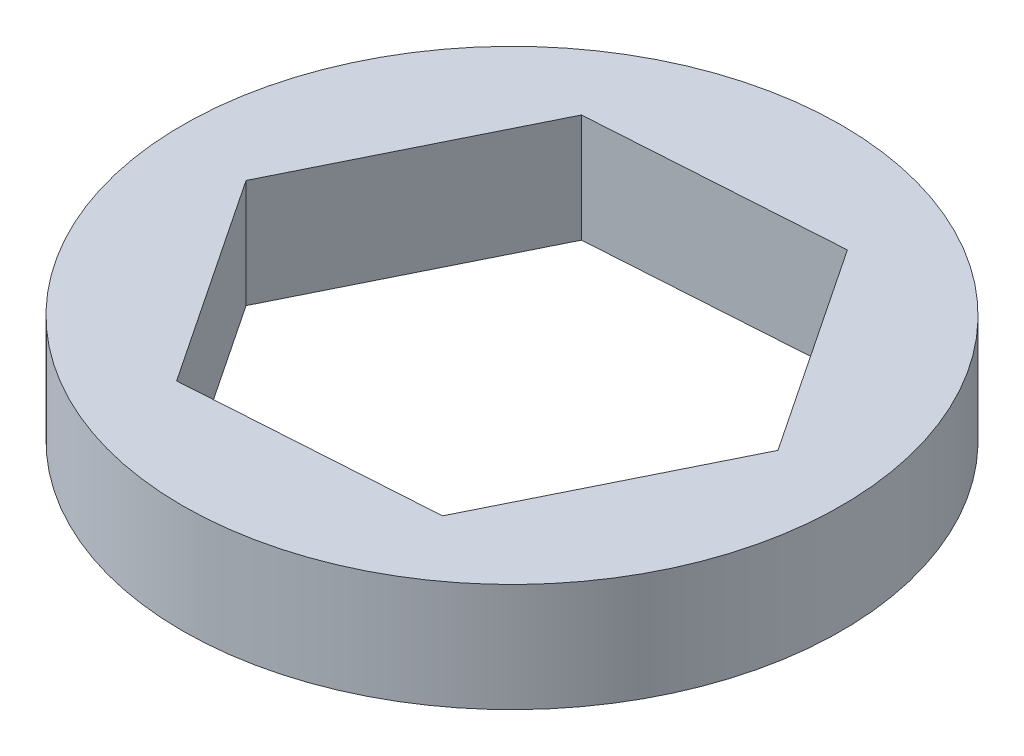
from build123d import *

# Parameters (mm, degrees)
SKETCH1_R           = 9.652
BOSS_EXTRUDE1_DEPTH = 3.175


with BuildPart() as part:
    # Sketch1 → Boss-Extrude1 (new body)
    with BuildSketch(Plane(origin=(0, 0, 0), x_dir=(1, 0, 0), z_dir=(0, 1, 0))):
        Circle(SKETCH1_R)
        Polygon((4.067255107, -6.10088266), (7.317146922, 0.471904916), (3.249891816, 6.572787576), (-4.067255107, 6.10088266), (-7.317146922, -0.471904916), (-3.249891816, -6.572787576), align=None, mode=Mode.SUBTRACT)
    extrude(amount=BOSS_EXTRUDE1_DEPTH)


solid = part.part
